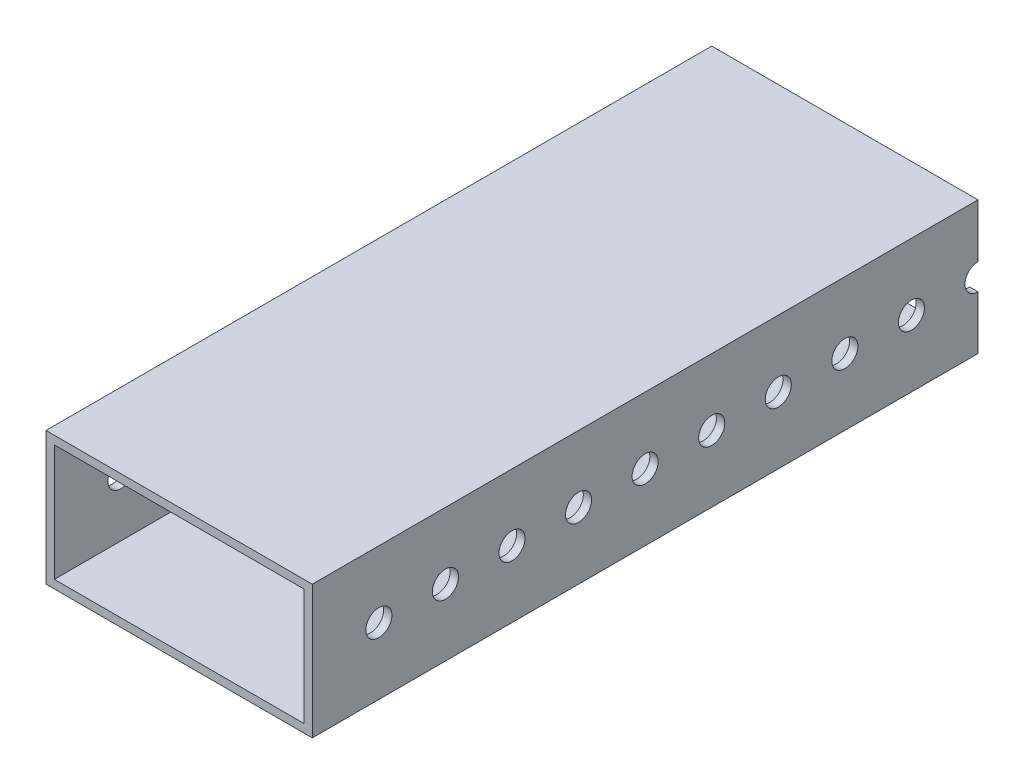
from build123d import *

# Parameters (mm, degrees)
SKETCH1_W           = 50.8
SKETCH1_H           = 25.4
SKETCH1_W_2         = 47.625
SKETCH1_H_2         = 22.225
BOSS_EXTRUDE1_DEPTH = 127
SKETCH2_R           = 2.4892
CUT_EXTRUDE1_DEPTH  = 51.8


with BuildPart() as part:
    # Sketch1 → Boss-Extrude1 (new body)
    with BuildSketch(Plane.XY):
        with Locations((25.4, 12.7)):
            Rectangle(SKETCH1_W, SKETCH1_H)
        with Locations((25.4, 12.7)):
            Rectangle(SKETCH1_W_2, SKETCH1_H_2, mode=Mode.SUBTRACT)
    extrude(amount=BOSS_EXTRUDE1_DEPTH)

    # Sketch2 → Cut-Extrude1 (cut, through all)
    with BuildSketch(Plane(origin=(50.8, 0, 0), x_dir=(0, 0, -1), z_dir=(1, 0, 0))):
        with Locations((-114.3, 12.7)):
            Circle(SKETCH2_R)
        with Locations((-101.6, 12.7)):
            Circle(SKETCH2_R)
        with Locations((-88.9, 12.7)):
            Circle(SKETCH2_R)
        with Locations((-76.2, 12.7)):
            Circle(SKETCH2_R)
        with Locations((-63.5, 12.7)):
            Circle(SKETCH2_R)
        with Locations((-50.8, 12.7)):
            Circle(SKETCH2_R)
        with Locations((-38.1, 12.7)):
            Circle(SKETCH2_R)
        with Locations((-25.4, 12.7)):
            Circle(SKETCH2_R)
        with Locations((-12.7, 12.7)):
            Circle(SKETCH2_R)
        with Locations((0, 12.7)):
            Circle(SKETCH2_R)
        with Locations((12.7, 12.7)):
            Circle(SKETCH2_R)
    extrude(amount=-CUT_EXTRUDE1_DEPTH, mode=Mode.SUBTRACT)


solid = part.part
